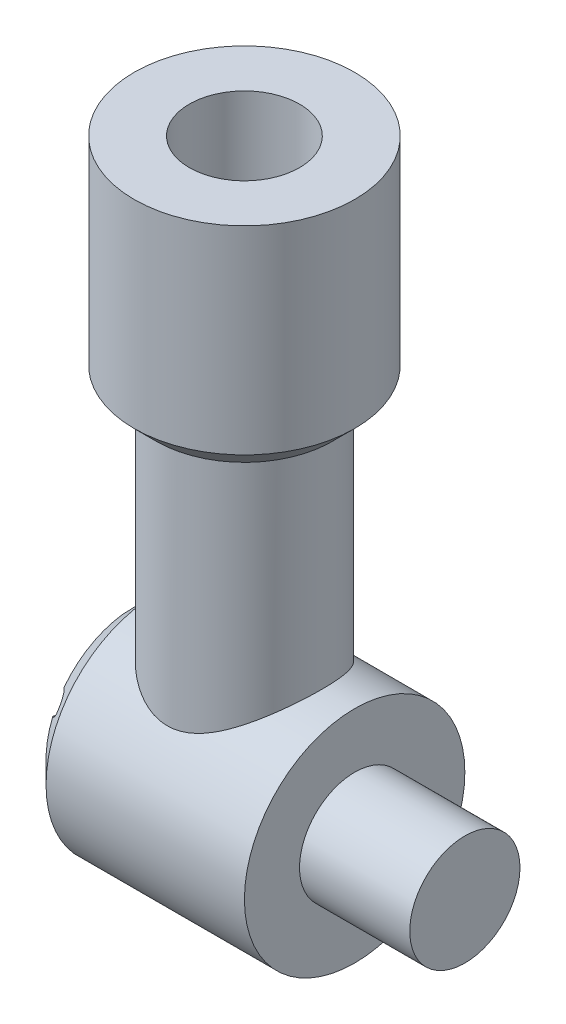
from build123d import *

# Parameters (mm, degrees)
SKETCH1_R           = 88.9
BOSS_EXTRUDE1_DEPTH = 152.4
SKETCH4_R           = 127
BOSS_EXTRUDE2_DEPTH = 127
SKETCH5_R           = 63.5
BOSS_EXTRUDE3_DEPTH = 127
SKETCH6_R           = 127
BOSS_EXTRUDE4_DEPTH = 254
SKETCH7_R           = 63.5
CUT_EXTRUDE1_DEPTH  = 127
CHAMFER1_SIZE       = 25.4
SKETCH8_R           = 12.7
CUT_EXTRUDE2_DEPTH  = 25.4
CHAMFER2_SIZE       = 25.4


with BuildPart() as part:
    # Sketch1 → Boss-Extrude1 (new body, symmetric)
    with BuildSketch(Plane(origin=(0, 0, 0), x_dir=(1, 0, 0), z_dir=(0, 1, 0))):
        Circle(SKETCH1_R)
    extrude(amount=BOSS_EXTRUDE1_DEPTH, both=True)

    # Sketch4 → Boss-Extrude2 (add, symmetric)
    with BuildSketch(Plane(origin=(0, 0, 0), x_dir=(0, 0, -1), z_dir=(1, 0, 0))):
        with Locations((0, -228.6)):
            Circle(SKETCH4_R)
    extrude(amount=BOSS_EXTRUDE2_DEPTH, both=True)

    # Sketch5 → Boss-Extrude3 (add)
    with BuildSketch(Plane(origin=(127, 0, 0), x_dir=(0, 0, -1), z_dir=(1, 0, 0))):
        with Locations((0, -228.6)):
            Circle(SKETCH5_R)
    extrude(amount=BOSS_EXTRUDE3_DEPTH)

    # Sketch6 → Boss-Extrude4 (add)
    with BuildSketch(Plane(origin=(0, 152.4, 0), x_dir=(1, 0, 0), z_dir=(0, 1, 0))):
        Circle(SKETCH6_R)
    extrude(amount=BOSS_EXTRUDE4_DEPTH)

    # Sketch7 → Cut-Extrude1 (cut)
    with BuildSketch(Plane(origin=(0, 406.4, 0), x_dir=(1, 0, 0), z_dir=(0, 1, 0))):
        Circle(SKETCH7_R)
    extrude(amount=-CUT_EXTRUDE1_DEPTH, mode=Mode.SUBTRACT)

    # Chamfer1
    chamfer1_edges = [part.edges().sort_by_distance(p)[0] for p in [
        (-127, -228.6, 127),
    ]]
    chamfer(chamfer1_edges, length=CHAMFER1_SIZE)

    # Sketch8 → Cut-Extrude2 (cut)
    with BuildSketch(Plane.ZY.offset(127)):
        with Locations((0, -127)):
            Circle(SKETCH8_R)
        with Locations((87.988181025, -177.8)):
            Circle(SKETCH8_R)
        with Locations((87.988181025, -279.4)):
            Circle(SKETCH8_R)
        with Locations((0, -330.2)):
            Circle(SKETCH8_R)
        with Locations((-87.988181024, -279.4)):
            Circle(SKETCH8_R)
        with Locations((-87.988181024, -177.8)):
            Circle(SKETCH8_R)
    extrude(amount=-CUT_EXTRUDE2_DEPTH, mode=Mode.SUBTRACT)

    # Chamfer2
    chamfer2_edges = [part.edges().sort_by_distance(p)[0] for p in [
        (-127, 152.4, 0),
    ]]
    chamfer(chamfer2_edges, length=CHAMFER2_SIZE)


solid = part.part
